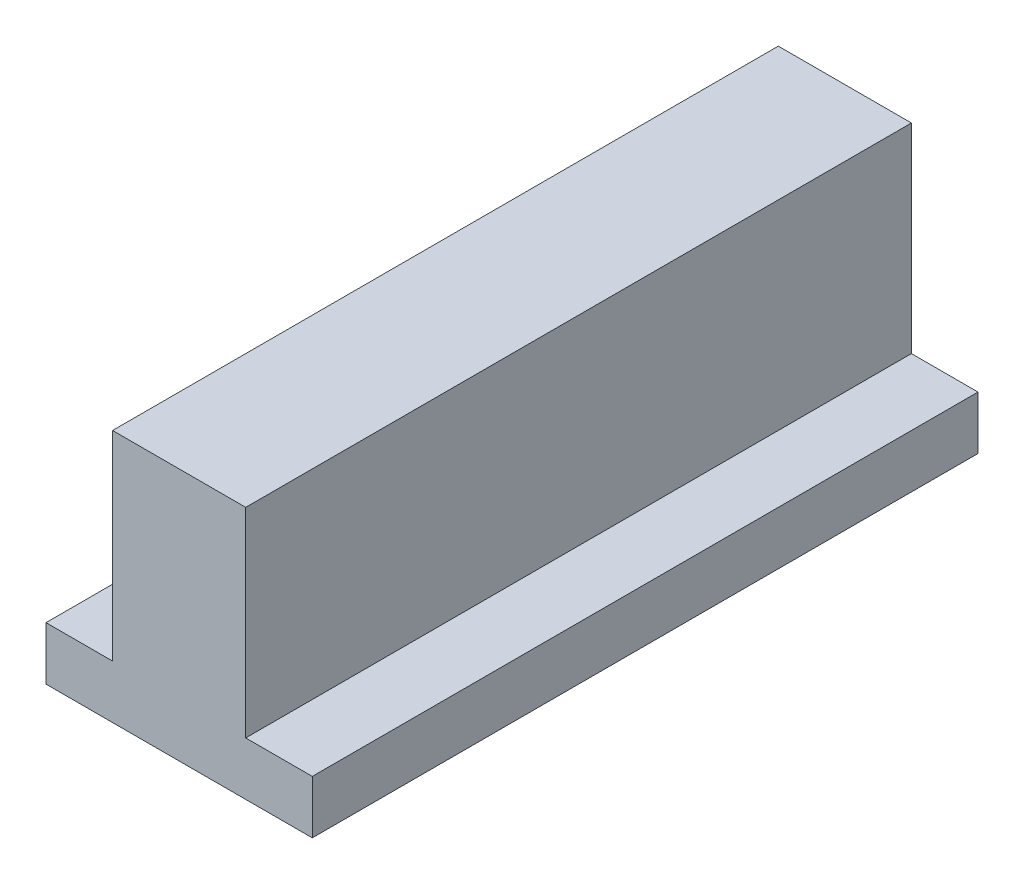
from build123d import *

# Parameters (mm, degrees)
BOSS_EXTRUDE1_DEPTH = 50


with BuildPart() as part:
    # Sketch1 → Boss-Extrude1 (new body)
    with BuildSketch(Plane.XY):
        Polygon((10, 0), (-10, 0), (-10, 4), (-5, 4), (-5, 9), (-5, 19), (5, 19), (5, 9), (5, 4), (10, 4), align=None)
    extrude(amount=BOSS_EXTRUDE1_DEPTH)


solid = part.part
